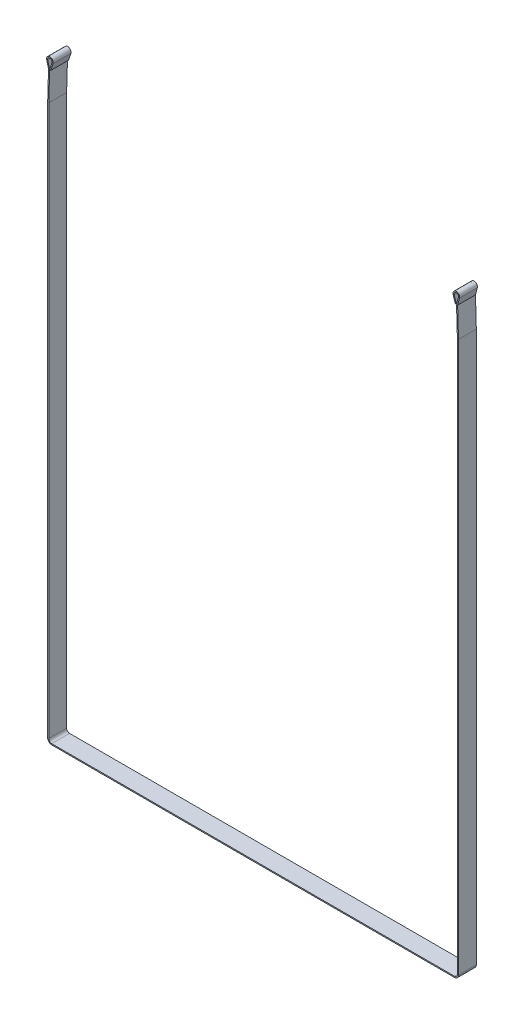
from build123d import *

# Parameters (mm, degrees)
EXTRU_MINCE1_DEPTH = 24


with BuildPart() as part:
    # Esquisse1 → Extru.-Mince1 (new body, symmetric)
    with BuildSketch(Plane.XY):
        with BuildLine():
            Line((547.565725672, -0.87294791), (541.301863245, 18.120841272))
            ThreePointArc((541.301863245, 18.120841272), (542.138161234, 23.516038085), (547, 26))
            ThreePointArc((547, 26), (551.756047412, 23.65787001), (552.799001066, 18.460004337))
            Line((552.799001066, 18.460004337), (547.665682189, -0.869999215))
            Line((547.665682189, -0.869999215), (550, -80))
            Line((550, -80), (550, -1562))
            ThreePointArc((550, -1562), (547.656854249, -1567.656854249), (542, -1570))
            Line((542, -1570), (-542, -1570))
            ThreePointArc((-542, -1570), (-547.656854249, -1567.656854249), (-550, -1562))
            Line((-550, -1562), (-550, -80))
            Line((-550, -80), (-547.665682189, -0.869999215))
            Line((-547.665682189, -0.869999215), (-552.799001066, 18.460004337))
            ThreePointArc((-552.799001066, 18.460004337), (-551.756047412, 23.65787001), (-547, 26))
            ThreePointArc((-547, 26), (-542.138161234, 23.516038085), (-541.301863245, 18.120841272))
            Line((-541.301863245, 18.120841272), (-547.565725672, -0.87294791))
            Line((-547.565725672, -0.87294791), (-544.716657295, -1.812527274))
            Line((-544.716657295, -1.812527274), (-538.452794868, 17.181261908))
            ThreePointArc((-538.452794868, 17.181261908), (-539.707241851, 25.274057128), (-547, 29))
            ThreePointArc((-547, 29), (-554.134071119, 25.486805015), (-555.698501598, 17.690006505))
            Line((-555.698501598, 17.690006505), (-550.677252807, -1.217986412))
            Line((-550.677252807, -1.217986412), (-553, -79.955759949))
            Line((-553, -79.955759949), (-553, -1562))
            ThreePointArc((-553, -1562), (-549.778174593, -1569.778174593), (-542, -1573))
            Line((-542, -1573), (542, -1573))
            ThreePointArc((542, -1573), (549.778174593, -1569.778174593), (553, -1562))
            Line((553, -1562), (553, -79.955759949))
            Line((553, -79.955759949), (550.677252807, -1.217986412))
            Line((550.677252807, -1.217986412), (555.698501598, 17.690006505))
            ThreePointArc((555.698501598, 17.690006505), (554.134071119, 25.486805015), (547, 29))
            ThreePointArc((547, 29), (539.707241851, 25.274057128), (538.452794868, 17.181261908))
            Line((538.452794868, 17.181261908), (544.716657295, -1.812527274))
            Line((544.716657295, -1.812527274), (547.565725672, -0.87294791))
        make_face()
    extrude(amount=EXTRU_MINCE1_DEPTH, both=True)


solid = part.part
